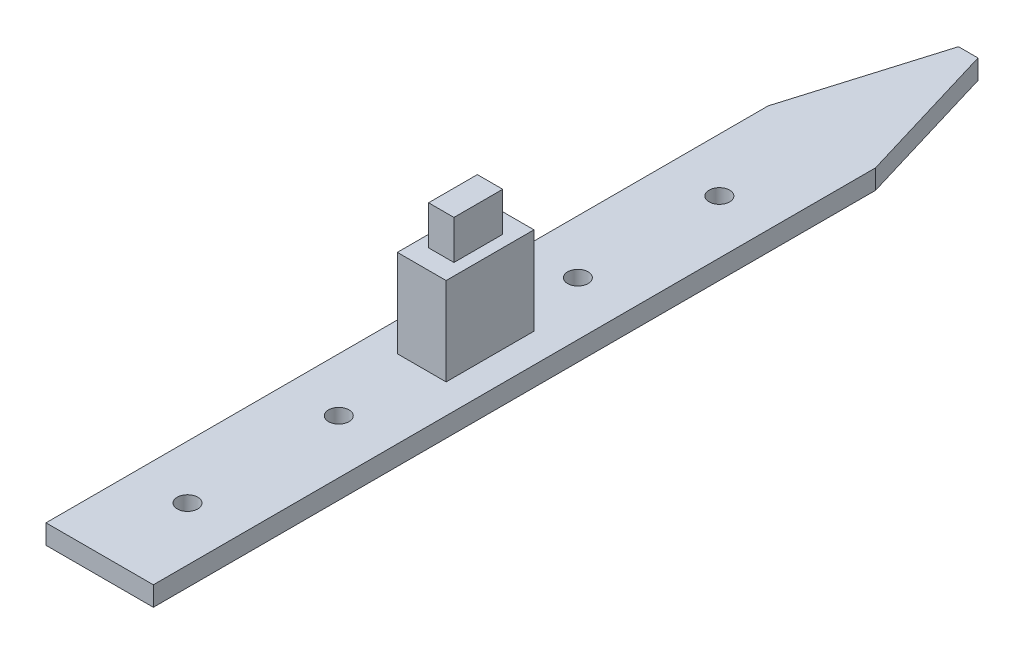
from build123d import *

# Parameters (mm, degrees)
BOSS_EXTRUDE1_DEPTH = 2
SKETCH3_R           = 1.05
CUT_EXTRUDE1_DEPTH  = 2
SKETCH4_W           = 5
SKETCH4_H           = 9
BOSS_EXTRUDE2_DEPTH = 9
SKETCH5_W           = 2.6
SKETCH5_H           = 5
BOSS_EXTRUDE3_DEPTH = 4


with BuildPart() as part:
    # Sketch2 → Boss-Extrude1 (new body)
    with BuildSketch(Plane(origin=(0, 0, 0), x_dir=(1, 0, 0), z_dir=(0, 1, 0))):
        Polygon((0, 0), (5.5, 0), (5.5, 89), (4.5, 89), (0, 74), align=None)
    extrude(amount=BOSS_EXTRUDE1_DEPTH)

    # Mirror1: part across plane


with BuildPart() as part_1:
    add(part.part)
    add(part.part.mirror(Plane(origin=(5.5, 2, 0), x_dir=(0, 0, 1), z_dir=(-1, 0, 0))))

    # Sketch3 → Cut-Extrude1 (cut)
    with BuildSketch(Plane(origin=(0, 2, 0), x_dir=(1, 0, 0), z_dir=(0, 1, 0))):
        with Locations((5.5, 9)):
            Circle(SKETCH3_R)
        with Locations((5.5, 24.5)):
            Circle(SKETCH3_R)
        with Locations((5.5, 49)):
            Circle(SKETCH3_R)
        with Locations((5.5, 63.5)):
            Circle(SKETCH3_R)
    extrude(amount=-CUT_EXTRUDE1_DEPTH, mode=Mode.SUBTRACT)

    # Sketch4 → Boss-Extrude2 (add)
    with BuildSketch(Plane(origin=(0, 2, 0), x_dir=(1, 0, 0), z_dir=(0, 1, 0))):
        with Locations((5.5, 37.5)):
            Rectangle(SKETCH4_W, SKETCH4_H)
    extrude(amount=BOSS_EXTRUDE2_DEPTH)

    # Sketch5 → Boss-Extrude3 (add)
    with BuildSketch(Plane(origin=(0, 11, 0), x_dir=(1, 0, 0), z_dir=(0, 1, 0))):
        with Locations((5.5, 37.5)):
            Rectangle(SKETCH5_W, SKETCH5_H)
    extrude(amount=BOSS_EXTRUDE3_DEPTH)


solid = part_1.part
